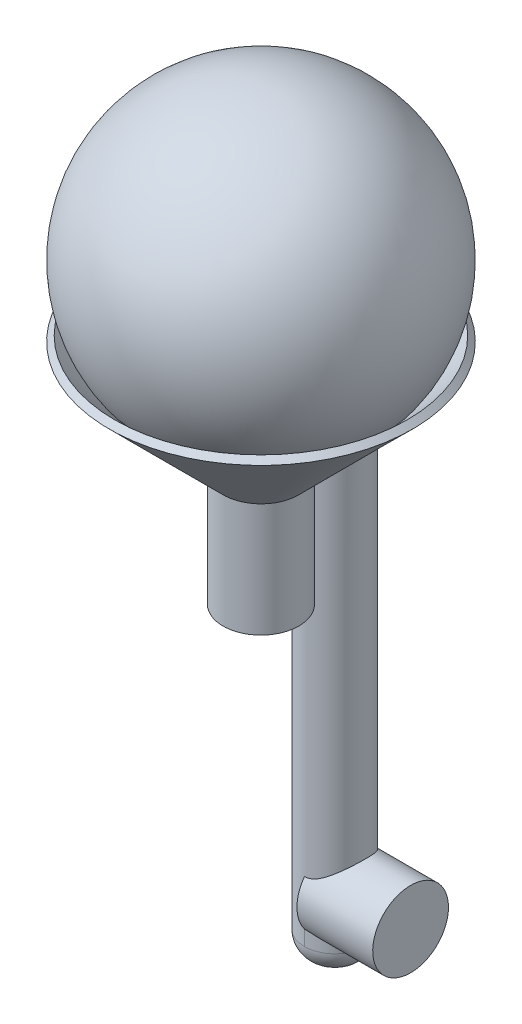
from build123d import *

# Parameters (mm, degrees)
BOSS_EXTRUDE1_REACH             = 46.32
SKETCH2_R                       = 4
BOSS_EXTRUDE1_DIRECTION_2_DEPTH = 60
FILLET1_R                       = 3
SKETCH3_R                       = 5
BOSS_EXTRUDE2_DEPTH             = 10


with BuildPart() as part:
    # Sketch1 → Revolve1 (revolve)
    with BuildSketch(Plane.XY):
        with BuildLine():
            Line((-5, 0), (-5, -15))
            Line((-5, -15), (-4, -15))
            Line((-4, -15), (-4, 0))
            Line((-4, 0), (0, 0))
            Line((0, 0), (0, 44.319820094))
            ThreePointArc((0, 44.319820094), (-17.789448167, 33.459597657), (-16.259159922, 12.673373485))
            Line((-16.259159922, 12.673373485), (-19.292893219, 15.707106781))
            Line((-19.292893219, 15.707106781), (-20, 15))
            Line((-20, 15), (-5, 0))
        make_face()
    revolve(axis=Axis((0, 0, 0), (0, 1, 0)))

    # Sketch2 → Boss-Extrude1 (add, up to next)
    with BuildSketch(Plane(origin=(0, 0, 0), x_dir=(1, 0, 0), z_dir=(0, 1, 0)), mode=Mode.PRIVATE) as boss_extrude1_sk1:
        with Locations((0, 9.747716973)):
            Circle(SKETCH2_R)
    boss_extrude1_tool1 = extrude(boss_extrude1_sk1.sketch, amount=BOSS_EXTRUDE1_REACH, mode=Mode.PRIVATE) - part.part
    add(boss_extrude1_tool1.solids().sort_by_distance((0, 0, -9.747717))[0])

    # Sketch2 → Boss-Extrude1 direction 2 (add)
    with BuildSketch(Plane(origin=(0, 0, 0), x_dir=(1, 0, 0), z_dir=(0, 1, 0))):
        with Locations((0, 9.747716973)):
            Circle(SKETCH2_R)
    extrude(amount=-BOSS_EXTRUDE1_DIRECTION_2_DEPTH)

    # Fillet1
    fillet1_edges = [part.edges().sort_by_distance(p)[0] for p in [
        (-4, -60, -9.747716973),
    ]]
    fillet(fillet1_edges, radius=FILLET1_R)

    # Sketch3 → Boss-Extrude2 (add)
    with BuildSketch(Plane(origin=(0, 0, 0), x_dir=(0, 0, -1), z_dir=(1, 0, 0))):
        with Locations((9.747716973, -52)):
            Circle(SKETCH3_R)
    extrude(amount=BOSS_EXTRUDE2_DEPTH)


solid = part.part
